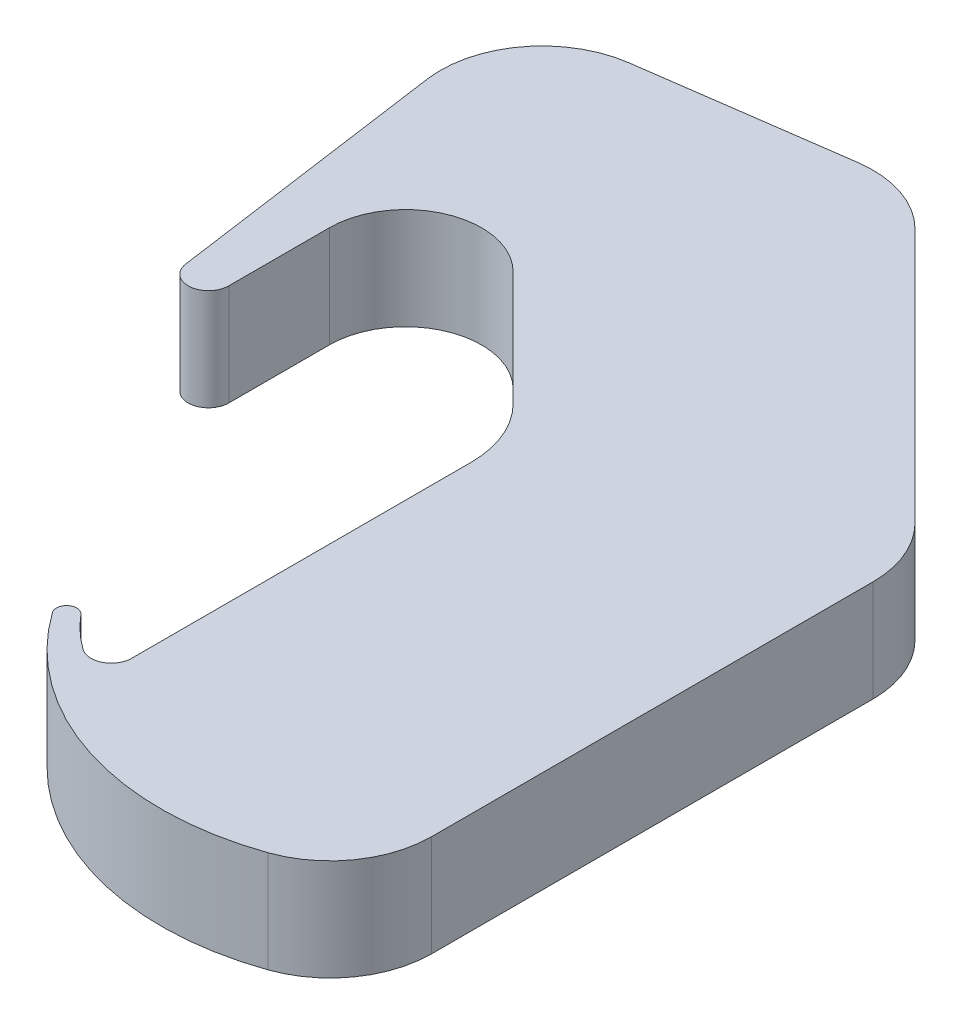
from build123d import *

# Parameters (mm, degrees)
SALIENTE_EXTRUIR1_DEPTH = 10
REDONDEO1_R             = 10
REDONDEO2_R             = 2


with BuildPart() as part:
    # Croquis1 → Saliente-Extruir1 (new body)
    with BuildSketch(Plane(origin=(0, 0, 0), x_dir=(1, 0, 0), z_dir=(0, 1, 0))):
        with BuildLine():
            Line((-55.595903629, 23.860424538), (-55.595903629, -17.139575462))
            ThreePointArc((-55.595903629, -17.139575462), (-58.988591813, -15.192930957), (-61.826379426, -12.500957814))
            ThreePointArc((-61.826379426, -12.500957814), (-63.205175994, -12.346614438), (-63.411183057, -13.718643208))
            ThreePointArc((-63.411183057, -13.718643208), (-45.832647936, -24.756705017), (-25.595903629, -20.139575462))
            Line((-25.595903629, -20.139575462), (-25.595903629, 33.458404285))
            Line((-25.595903629, 33.458404285), (-57.189073116, 65.051573772))
            Line((-57.189073116, 65.051573772), (-91.850363788, 60.194112608))
            Line((-91.850363788, 60.194112608), (-86.576548855, 22.561854481))
            ThreePointArc((-86.576548855, 22.561854481), (-84.456782192, 20.844267935), (-82.595903629, 22.839423374))
            Line((-82.595903629, 22.839423374), (-82.595903629, 32.75382282))
            ThreePointArc((-82.595903629, 32.75382282), (-77.966029372, 39.682919314), (-69.79260277, 38.057123679))
            Line((-69.79260277, 38.057123679), (-55.595903629, 23.860424538))
        make_face()
    extrude(amount=SALIENTE_EXTRUIR1_DEPTH)

    # Redondeo1
    redondeo1_edges = [part.edges().sort_by_distance(p)[0] for p in [
        (-25.595903629, 5, -33.458404285),
        (-25.595903629, 5, 20.139575462),
        (-55.595903629, 5, -23.860424538),
        (-91.850363788, 5, -60.194112608),
        (-57.189073116, 5, -65.051573772),
    ]]
    fillet(redondeo1_edges, radius=REDONDEO1_R)

    # Redondeo2
    redondeo2_edges = [part.edges().sort_by_distance(p)[0] for p in [
        (-55.595903629, 5, 17.139575462),
    ]]
    fillet(redondeo2_edges, radius=REDONDEO2_R)


solid = part.part
